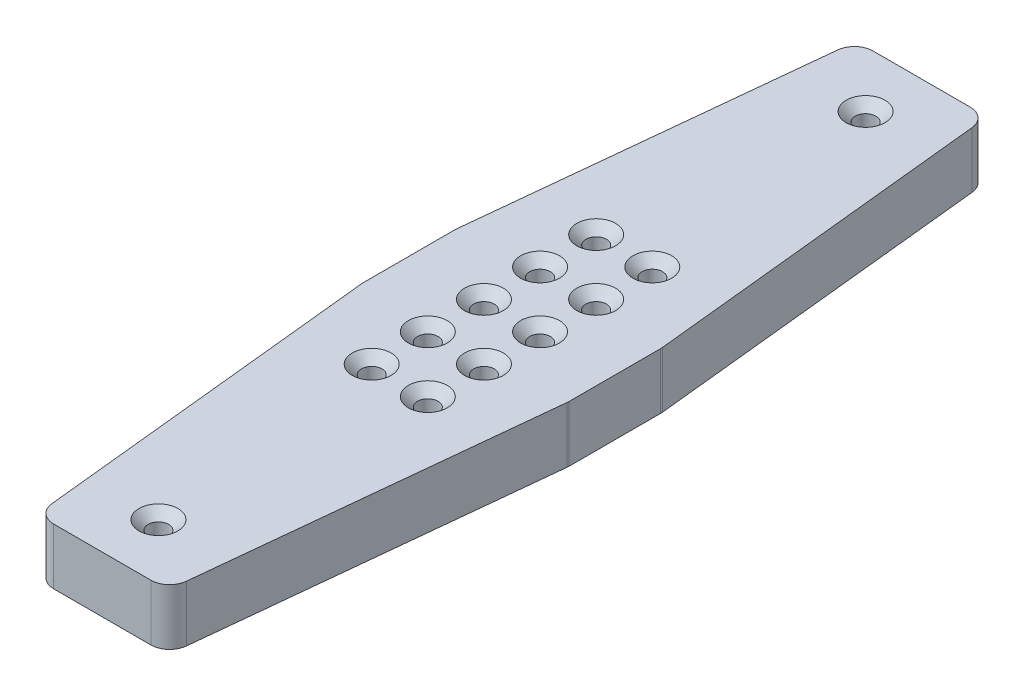
from build123d import *

# Parameters (mm, degrees)
BOSS_EXTRU_1_DEPTH                             = 15
FRAISAGE_POUR_VIS_T_TE_FRAIS_E_M51_D           = 5.5
FRAISAGE_POUR_VIS_T_TE_FRAIS_E_M51_CSINK_D     = 10.4
FRAISAGE_POUR_VIS_T_TE_FRAIS_E_M51_CSINK_ANGLE = 90
CONG_2_R                                       = 5


with BuildPart() as part:
    # Esquisse1 → Boss.-Extru.1 (new body)
    with BuildSketch(Plane(origin=(0, 0, 0), x_dir=(1, 0, 0), z_dir=(0, 1, 0))):
        Polygon((-17.5, 109.5), (-27.5, 12.5), (-27.5, -12.5), (-17.5, -109.5), (17.5, -109.5), (27.5, -12.5), (27.5, 12.5), (17.5, 109.5), align=None)
    extrude(amount=BOSS_EXTRU_1_DEPTH)

    # Fraisage pour vis à tête fraisée M51 (through all)
    with Locations(Plane(origin=(0, 15, 0), x_dir=(1, 0, 0), z_dir=(0, 1, 0))):
        with Locations((-7.5, 30), (7.5, 30), (7.5, 15), (-7.5, 15), (-7.5, 0), (7.5, 0), (7.5, -15), (-7.5, -15), (-7.5, -30), (7.5, -30), (0, -94.5), (0, 94.5)):
            CounterSinkHole(FRAISAGE_POUR_VIS_T_TE_FRAIS_E_M51_D / 2, FRAISAGE_POUR_VIS_T_TE_FRAIS_E_M51_CSINK_D / 2, counter_sink_angle=FRAISAGE_POUR_VIS_T_TE_FRAIS_E_M51_CSINK_ANGLE)

    # Congé2
    cong_2_edges = [part.edges().sort_by_distance(p)[0] for p in [
        (27.5, 7.5, -12.5),
        (27.5, 7.5, 12.5),
        (17.5, 7.5, 109.5),
        (-17.5, 7.5, 109.5),
        (-27.5, 7.5, 12.5),
        (-27.5, 7.5, -12.5),
        (-17.5, 7.5, -109.5),
        (17.5, 7.5, -109.5),
    ]]
    fillet(cong_2_edges, radius=CONG_2_R)


solid = part.part
